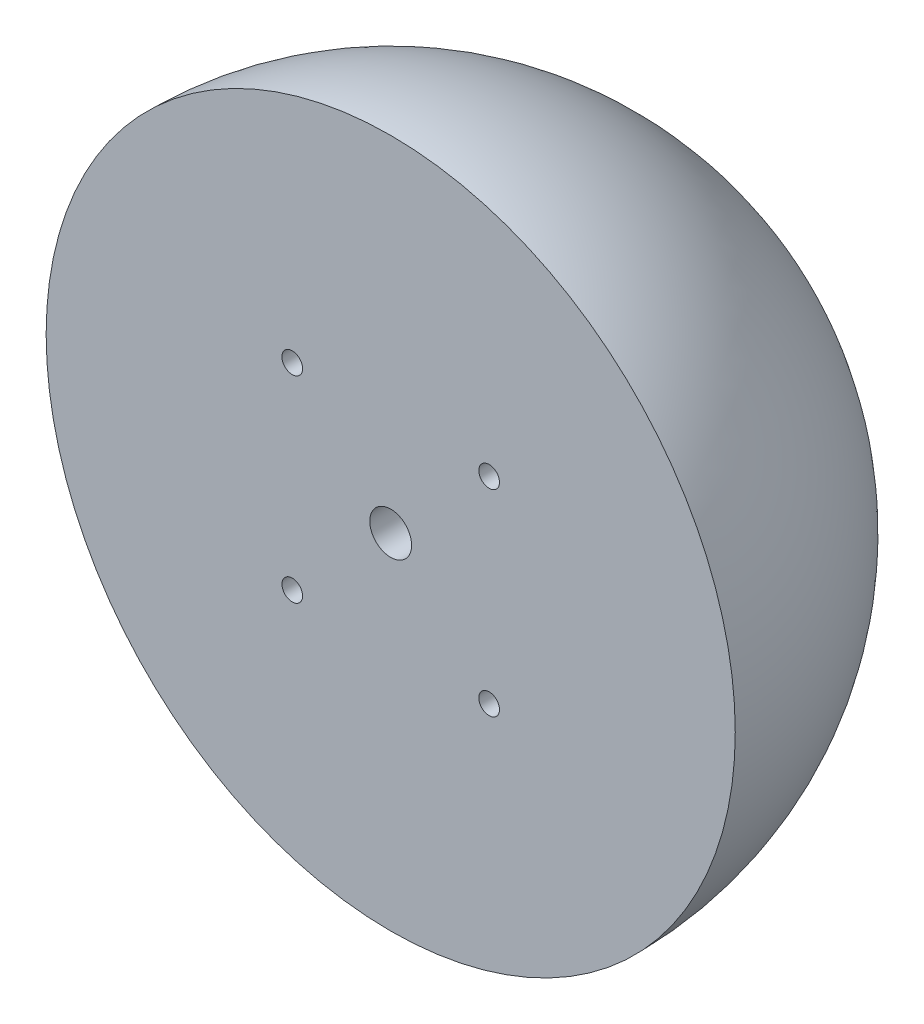
from build123d import *

# Parameters (mm, degrees)
M10_TAPPED_HOLE1_D     = 8.5
M10_TAPPED_HOLE1_DEPTH = 30
M10_TAPPED_HOLE1_TIP   = 2.553657631
M5_TAPPED_HOLE1_D      = 4.2
M5_TAPPED_HOLE1_DEPTH  = 20
M5_TAPPED_HOLE1_TIP    = 1.2618073


with BuildPart() as part:
    # Sketch2 → Revolve1 (revolve)
    with BuildSketch(Plane(origin=(0, 0, 0), x_dir=(1, 0, 0), z_dir=(0, 1, 0))):
        with BuildLine():
            Line((0, 70), (0, 0))
            Line((0, 0), (70, 0))
            ThreePointArc((70, 0), (49.497474683, 49.497474683), (0, 70))
        make_face()
    revolve(axis=Axis((0, 0, -70), (0, 0, 1)))

    # M10 Tapped Hole1
    with Locations(Plane.XY):
        with Locations((0, 0)):
            Hole(M10_TAPPED_HOLE1_D / 2, depth=M10_TAPPED_HOLE1_DEPTH)
            with Locations((0, 0, -(M10_TAPPED_HOLE1_DEPTH + M10_TAPPED_HOLE1_TIP / 2))):  # 118° drill point
                Cone(0, M10_TAPPED_HOLE1_D / 2, M10_TAPPED_HOLE1_TIP, mode=Mode.SUBTRACT)

    # M5 Tapped Hole1
    with Locations(Plane.XY):
        with Locations((-20, 20), (20, 20), (20, -20), (-20, -20)):
            Hole(M5_TAPPED_HOLE1_D / 2, depth=M5_TAPPED_HOLE1_DEPTH)
            with Locations((0, 0, -(M5_TAPPED_HOLE1_DEPTH + M5_TAPPED_HOLE1_TIP / 2))):  # 118° drill point
                Cone(0, M5_TAPPED_HOLE1_D / 2, M5_TAPPED_HOLE1_TIP, mode=Mode.SUBTRACT)


solid = part.part
